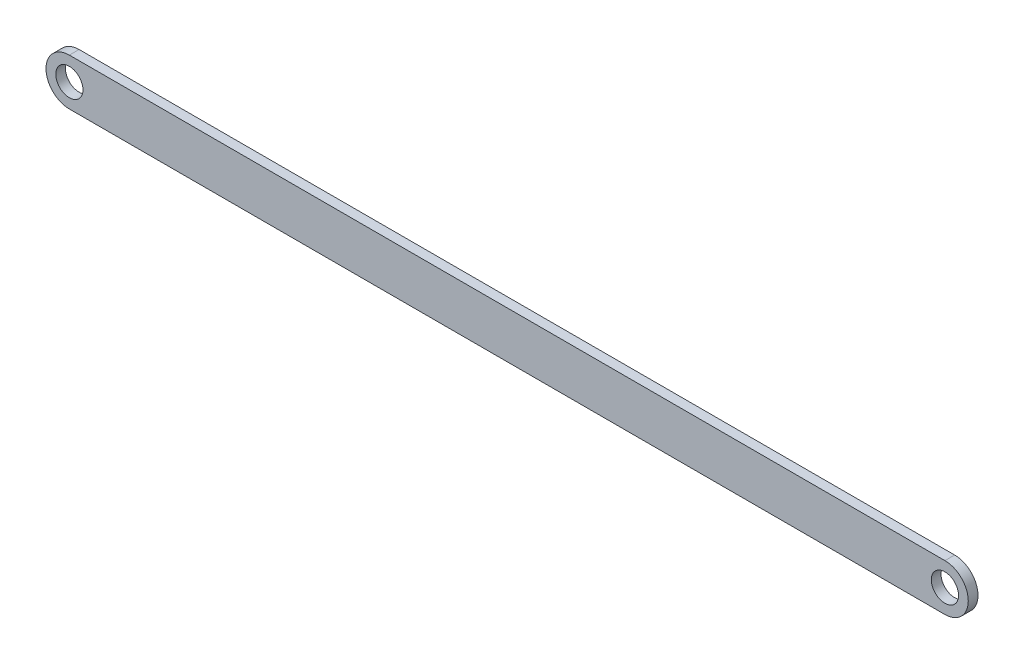
from build123d import *

# Parameters (mm, degrees)
DODANIE_WYCI_GNI_CIE1_DEPTH = 5
SZKIC2_R                    = 7
WYTNIJ_WYCI_GNI_CIE1_DEPTH  = 5


with BuildPart() as part:
    # Szkic1 → Dodanie-wyciągnięcie1 (new body)
    with BuildSketch(Plane.XY):
        with BuildLine():
            Line((0, 0), (450, 0))
            ThreePointArc((450, 0), (462, 12), (450, 24))
            Line((450, 24), (0, 24))
            ThreePointArc((0, 24), (-12, 12), (0, 0))
        make_face()
    extrude(amount=DODANIE_WYCI_GNI_CIE1_DEPTH)

    # Szkic2 → Wytnij-wyciągnięcie1 (cut)
    with BuildSketch(Plane.XY.offset(5)):
        with Locations((0, 12)):
            Circle(SZKIC2_R)
        with Locations((450, 12)):
            Circle(SZKIC2_R)
    extrude(amount=-WYTNIJ_WYCI_GNI_CIE1_DEPTH, mode=Mode.SUBTRACT)


solid = part.part
